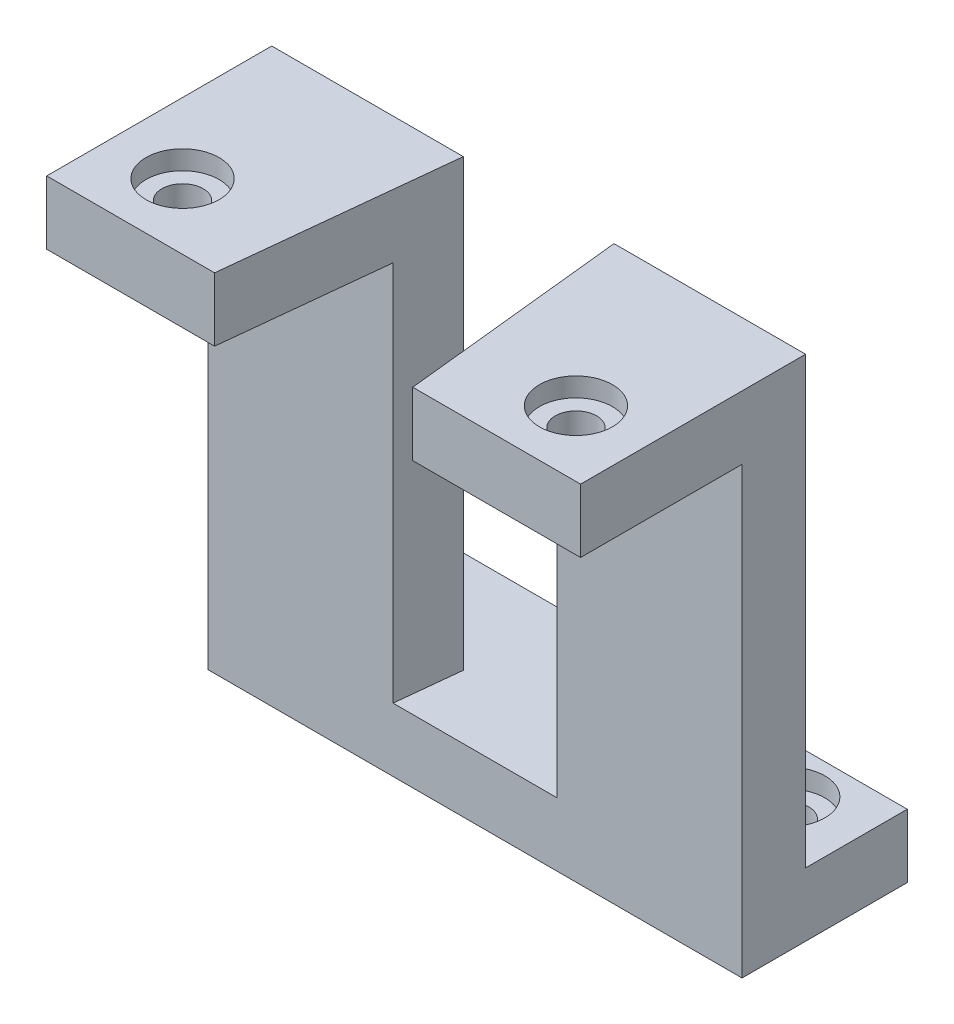
from build123d import *

# Parameters (mm, degrees)
SKETCH2_R           = 1.625
BOSS_EXTRUDE1_DEPTH = 10
SKETCH3_R           = 2.875
CUT_EXTRUDE1_DEPTH  = 1.5
SKETCH4_W           = 42
SKETCH4_H           = 5
BOSS_EXTRUDE2_DEPTH = 30
SKETCH5_W           = 42
SKETCH5_H           = 5
BOSS_EXTRUDE3_DEPTH = 8
CUT_EXTRUDE2_REACH  = 44
SKETCH6_W           = 12.701613413
SKETCH6_H           = 5
CUT_EXTRUDE3_REACH  = 7
SKETCH8_R           = 1.625
SKETCH9_R           = 2.875
CUT_EXTRUDE4_DEPTH  = 1.5
CUT_EXTRUDE5_DEPTH  = 35


with BuildPart() as part:
    # Sketch2 → Boss-Extrude1 (new body)
    with BuildSketch(Plane(origin=(0, 0, 0), x_dir=(1, 0, 0), z_dir=(0, 1, 0))):
        Polygon((-21, 4.97717469), (-21, -4.97717469), (21, -4.97717469), (21, 4.97717469), (21, 12.724438723), (-21, 12.724438723), align=None)
        with Locations((-15.475, 0.182409544)):
            Circle(SKETCH2_R, mode=Mode.SUBTRACT)
        with Locations((15.475, 0.182409544)):
            Circle(SKETCH2_R, mode=Mode.SUBTRACT)
    extrude(amount=BOSS_EXTRUDE1_DEPTH)

    # Sketch3 → Cut-Extrude1 (cut)
    with BuildSketch(Plane(origin=(0, 10, 0), x_dir=(1, 0, 0), z_dir=(0, 1, 0))):
        with Locations((-15.475, 0.182409544)):
            Circle(SKETCH3_R)
        with Locations((15.475, 0.182409544)):
            Circle(SKETCH3_R)
    extrude(amount=-CUT_EXTRUDE1_DEPTH, mode=Mode.SUBTRACT)

    # Sketch4 → Boss-Extrude2 (add)
    with BuildSketch(Plane.XZ):
        with Locations((0, -10.224438723)):
            Rectangle(SKETCH4_W, SKETCH4_H)
    extrude(amount=BOSS_EXTRUDE2_DEPTH)

    # Sketch5 → Boss-Extrude3 (add)
    with BuildSketch(Plane(origin=(0, 0, -12.724438723), x_dir=(-1, 0, 0), z_dir=(0, 0, -1))):
        with Locations((0, -27.5)):
            Rectangle(SKETCH5_W, SKETCH5_H)
    extrude(amount=BOSS_EXTRUDE3_DEPTH)

    # Sketch6 → Cut-Extrude2 (cut, up to next)
    with BuildSketch(Plane.ZY.offset(21), mode=Mode.PRIVATE) as cut_extrude2_sk1:
        with Locations((-1.373632017, 2.5)):
            Rectangle(SKETCH6_W, SKETCH6_H)
    cut_extrude2_tool1 = extrude(cut_extrude2_sk1.sketch, amount=-CUT_EXTRUDE2_REACH, mode=Mode.PRIVATE) & part.part
    add(cut_extrude2_tool1.solids().sort_by_distance((-21, 2.5, -1.373632))[0], mode=Mode.SUBTRACT)

    # Sketch8 → Cut-Extrude3 (cut, up to next)
    with BuildSketch(Plane(origin=(0, -25, 0), x_dir=(1, 0, 0), z_dir=(0, 1, 0)), mode=Mode.PRIVATE) as cut_extrude3_sk1:
        with Locations((-15.475, 16.884966607)):
            Circle(SKETCH8_R)
    cut_extrude3_tool1 = extrude(cut_extrude3_sk1.sketch, amount=-CUT_EXTRUDE3_REACH, mode=Mode.PRIVATE) & part.part
    add(cut_extrude3_tool1.solids().sort_by_distance((-15.475, -25, -16.884967))[0], mode=Mode.SUBTRACT)
    # Sketch8 → Cut-Extrude3 (cut, up to next)
    with BuildSketch(Plane(origin=(0, -25, 0), x_dir=(1, 0, 0), z_dir=(0, 1, 0)), mode=Mode.PRIVATE) as cut_extrude3_sk2:
        with Locations((15.475, 16.884966607)):
            Circle(SKETCH8_R)
    cut_extrude3_tool2 = extrude(cut_extrude3_sk2.sketch, amount=-CUT_EXTRUDE3_REACH, mode=Mode.PRIVATE) & part.part
    add(cut_extrude3_tool2.solids().sort_by_distance((15.475, -25, -16.884967))[0], mode=Mode.SUBTRACT)

    # Sketch9 → Cut-Extrude4 (cut)
    with BuildSketch(Plane(origin=(0, -25, 0), x_dir=(1, 0, 0), z_dir=(0, 1, 0))):
        with Locations((-15.475, 16.884966607)):
            Circle(SKETCH9_R)
        with Locations((15.475, 16.884966607)):
            Circle(SKETCH9_R)
    extrude(amount=-CUT_EXTRUDE4_DEPTH, mode=Mode.SUBTRACT)

    # Sketch11 → Cut-Extrude5 (cut)
    with BuildSketch(Plane(origin=(0, 10, 0), x_dir=(1, 0, 0), z_dir=(0, 1, 0))):
        Polygon((-7.795347272, -4.97717469), (-5.927938177, 12.724438723), (5.927938177, 12.724438723), (7.795347272, -4.97717469), align=None)
    extrude(amount=-CUT_EXTRUDE5_DEPTH, mode=Mode.SUBTRACT)


solid = part.part
